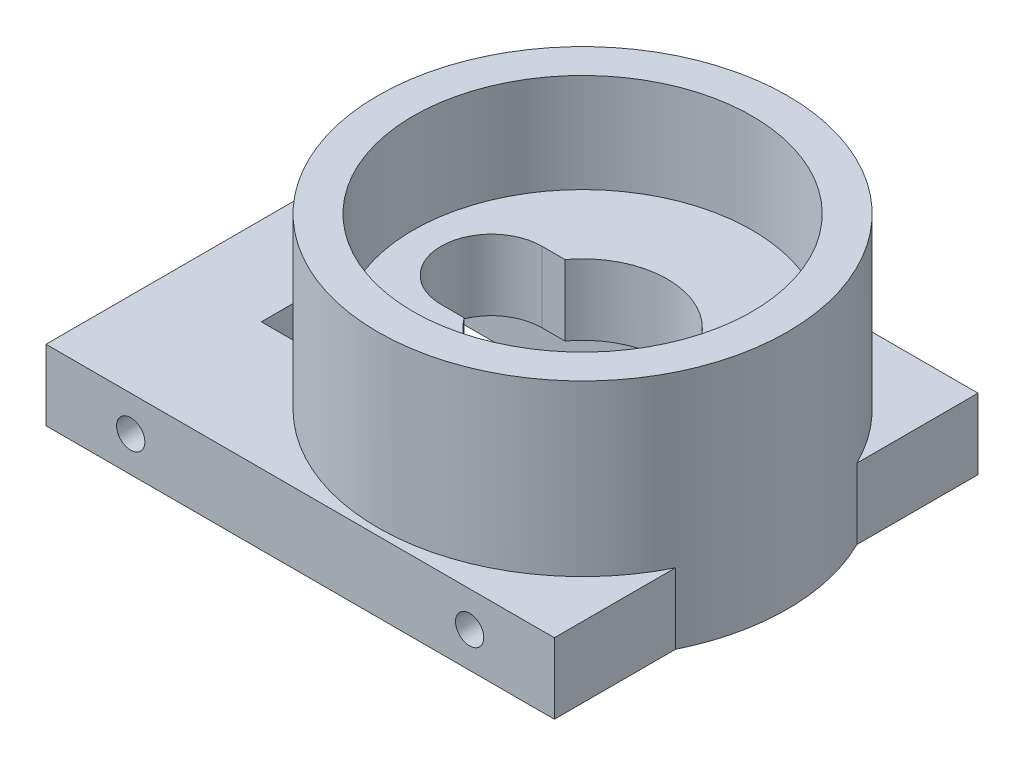
from build123d import *

# Parameters (mm, degrees)
SKETCH_1_W               = 36
SKETCH_1_H               = 30
EXTRUDE_1_DEPTH          = 5
SKETCH_2_R               = 14.5
EXTRUDE_2_DEPTH          = 17
SKETCH_4_W               = 33
SKETCH_4_H               = 12
CUT_EXTRUDE_2_DEPTH      = 2
SKETCH_8_R               = 1
CUT_EXTRUDE_6_DEPTH      = 3
SKETCH_5_W               = 23.5
SKETCH_5_H               = 12
CUT_EXTRUDE_3_DEPTH      = 3
CUT_EXTRUDE_3_DEPTH_BACK = 3
SKETCH_3_R               = 12
CUT_EXTRUDE_1_DEPTH      = 7
SKETCH_6_R               = 6
CUT_EXTRUDE_4_DEPTH      = 5
CUT_EXTRUDE_5_DEPTH      = 5
SKETCH_9_R               = 1
CUT_EXTRUDE_7_DEPTH      = 5


with BuildPart() as part:
    # 草图1 → 凸台-拉伸1 (new body)
    with BuildSketch(Plane(origin=(0, 0, 0), x_dir=(1, 0, 0), z_dir=(0, 1, 0))):
        Rectangle(SKETCH_1_W, SKETCH_1_H)
    extrude(amount=EXTRUDE_1_DEPTH)

    # 草图2 → 凸台-拉伸2 (add)
    with BuildSketch(Plane.XZ):
        with Locations((5, 0)):
            Circle(SKETCH_2_R)
    extrude(amount=-EXTRUDE_2_DEPTH)

    # 草图4 → 切除-拉伸2 (cut)
    with BuildSketch(Plane.XZ):
        Rectangle(SKETCH_4_W, SKETCH_4_H)
    extrude(amount=-CUT_EXTRUDE_2_DEPTH, mode=Mode.SUBTRACT)

    # 草图8 → 切除-拉伸6 (cut)
    with BuildSketch(Plane.XZ.offset(-2)):
        with Locations((14, 0)):
            Circle(SKETCH_8_R)
        with Locations((-14, 0)):
            Circle(SKETCH_8_R)
    extrude(amount=-CUT_EXTRUDE_6_DEPTH, mode=Mode.SUBTRACT)

    # 草图5 → 切除-拉伸3 (cut, two sides)
    with BuildSketch(Plane.XZ.offset(-2)) as cut_extrude_3_sk:
        Rectangle(SKETCH_5_W, SKETCH_5_H)
    extrude(amount=CUT_EXTRUDE_3_DEPTH, mode=Mode.SUBTRACT)
    extrude(cut_extrude_3_sk.sketch, amount=-CUT_EXTRUDE_3_DEPTH_BACK, mode=Mode.SUBTRACT)

    # 草图3 → 切除-拉伸1 (cut)
    with BuildSketch(Plane(origin=(0, 17, 0), x_dir=(1, 0, 0), z_dir=(0, 1, 0))):
        with Locations((5, 0)):
            Circle(SKETCH_3_R)
    extrude(amount=-CUT_EXTRUDE_1_DEPTH, mode=Mode.SUBTRACT)

    # 草图6 → 切除-拉伸4 (cut)
    with BuildSketch(Plane(origin=(0, 10, 0), x_dir=(1, 0, 0), z_dir=(0, 1, 0))):
        with Locations((5, 0)):
            Circle(SKETCH_6_R)
    extrude(amount=-CUT_EXTRUDE_4_DEPTH, mode=Mode.SUBTRACT)

    # 草图7 → 切除-拉伸5 (cut)
    with BuildSketch(Plane(origin=(0, 10, 0), x_dir=(1, 0, 0), z_dir=(0, 1, 0))):
        with BuildLine():
            Line((-1.455492537, 3.570915288), (2.115422752, 3.570915288))
            Line((2.115422752, 3.570915288), (2.115422752, -3.570915288))
            Line((2.115422752, -3.570915288), (-1.455492537, -3.570915288))
            ThreePointArc((-1.455492537, -3.570915288), (-5.026407825, 0), (-1.455492537, 3.570915288))
        make_face()
    extrude(amount=-CUT_EXTRUDE_5_DEPTH, mode=Mode.SUBTRACT)

    # 草图9 → 切除-拉伸7 (cut)
    with BuildSketch(Plane(origin=(0, 0, -15), x_dir=(-1, 0, 0), z_dir=(0, 0, -1))):
        with Locations((12, 2.5)):
            Circle(SKETCH_9_R)
        with Locations((-12, 2.5)):
            Circle(SKETCH_9_R)
    cut_extrude_7 = extrude(amount=-CUT_EXTRUDE_7_DEPTH, mode=Mode.SUBTRACT)

    # 镜向1: 切除-拉伸7 across plane
    add(cut_extrude_7.mirror(Plane.XY), mode=Mode.SUBTRACT)


solid = part.part
